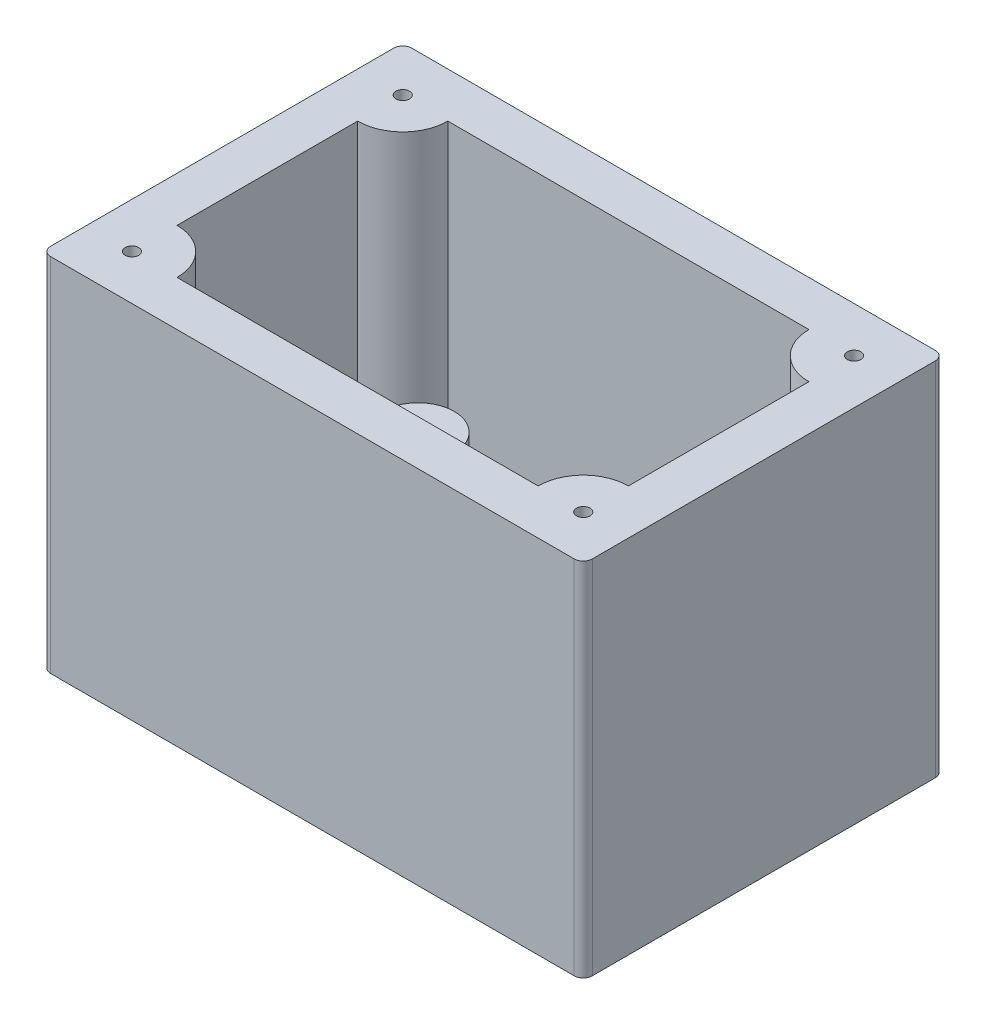
from build123d import *

# Parameters (mm, degrees)
SKETCH1_W           = 50
SKETCH1_H           = 30
BOSS_EXTRUDE1_DEPTH = 5
SKETCH1_3_W         = 60
SKETCH1_3_H         = 40
SKETCH1_3_W_2       = 50
SKETCH1_3_H_2       = 30
BOSS_EXTRUDE2_DEPTH = 40
SKETCH2_R           = 4
BOSS_EXTRUDE3_DEPTH = 10
SKETCH6_R           = 0.75
CUT_EXTRUDE1_DEPTH  = 5
FILLET1_R           = 1.5
BOSS_EXTRUDE4_START = -1e-06
BOSS_EXTRUDE4_DEPTH = 35.000001
SKETCH10_R          = 0.75
CUT_EXTRUDE2_DEPTH  = 10
FILLET2_R           = 1


with BuildPart() as part:
    # Sketch1 → Boss-Extrude1 (new body)
    with BuildSketch(Plane(origin=(0, 0, 0), x_dir=(1, 0, 0), z_dir=(0, 1, 0))):
        with Locations((25, -15)):
            Rectangle(SKETCH1_W, SKETCH1_H)
    extrude(amount=BOSS_EXTRUDE1_DEPTH)

    # Sketch1_3 → Boss-Extrude2 (add)
    with BuildSketch(Plane(origin=(0, 0, 0), x_dir=(1, 0, 0), z_dir=(0, 1, 0))):
        with Locations((25, -15)):
            Rectangle(SKETCH1_3_W, SKETCH1_3_H)
        with Locations((25, -15)):
            Rectangle(SKETCH1_3_W_2, SKETCH1_3_H_2, mode=Mode.SUBTRACT)
    extrude(amount=BOSS_EXTRUDE2_DEPTH)

    # Sketch2 → Boss-Extrude3 (add)
    with BuildSketch(Plane(origin=(0, 5, 0), x_dir=(1, 0, 0), z_dir=(0, 1, 0))):
        with Locations((8.2, -6.5)):
            Circle(SKETCH2_R)
        with Locations((41.8, -23.5)):
            Circle(SKETCH2_R)
    extrude(amount=BOSS_EXTRUDE3_DEPTH)

    # Sketch6 → Cut-Extrude1 (cut)
    with BuildSketch(Plane(origin=(0, 15, 0), x_dir=(1, 0, 0), z_dir=(0, 1, 0))):
        with Locations((41.8, -23.4)):
            Circle(SKETCH6_R)
        with Locations((8.1, -6.6)):
            Circle(SKETCH6_R)
    extrude(amount=-CUT_EXTRUDE1_DEPTH, mode=Mode.SUBTRACT)

    # Fillet1
    fillet1_edges = [part.edges().sort_by_distance(p)[0] for p in [
        (4.2, 5, 6.5),
        (37.8, 5, 23.5),
    ]]
    fillet(fillet1_edges, radius=FILLET1_R)

    # Sketch9 → Boss-Extrude4 (add)
    with BuildSketch(Plane(origin=(0, 5, 0), x_dir=(1, 0, 0), z_dir=(0, 1, 0)).offset(BOSS_EXTRUDE4_START)):
        with BuildLine():
            Line((5, 0), (0, 0))
            Line((0, 0), (0, -5))
            ThreePointArc((0, -5), (3.535533906, -3.535533906), (5, 0))
        make_face()
        with BuildLine():
            Line((50, -5), (50, 0))
            Line((50, 0), (45, 0))
            ThreePointArc((45, 0), (46.464466094, -3.535533906), (50, -5))
        make_face()
        with BuildLine():
            Line((45, -30), (50, -30))
            Line((50, -30), (50, -25))
            ThreePointArc((50, -25), (46.464466094, -26.464466094), (45, -30))
        make_face()
        with BuildLine():
            Line((0, -25), (0, -30))
            Line((0, -30), (5, -30))
            ThreePointArc((5, -30), (3.535533906, -26.464466094), (0, -25))
        make_face()
    extrude(amount=BOSS_EXTRUDE4_DEPTH)

    # Sketch10 → Cut-Extrude2 (cut)
    with BuildSketch(Plane(origin=(0, 40, 0), x_dir=(1, 0, 0), z_dir=(0, 1, 0))):
        with Locations((50, -30)):
            Circle(SKETCH10_R)
        with Locations((0, -30)):
            Circle(SKETCH10_R)
        with Locations((50, 0)):
            Circle(SKETCH10_R)
        Circle(SKETCH10_R)
    extrude(amount=-CUT_EXTRUDE2_DEPTH, mode=Mode.SUBTRACT)

    # Fillet2
    fillet2_edges = [part.edges().sort_by_distance(p)[0] for p in [
        (-5, 20, -5),
        (-5, 20, 35),
        (55, 20, 35),
        (55, 20, -5),
    ]]
    fillet(fillet2_edges, radius=FILLET2_R)


solid = part.part
